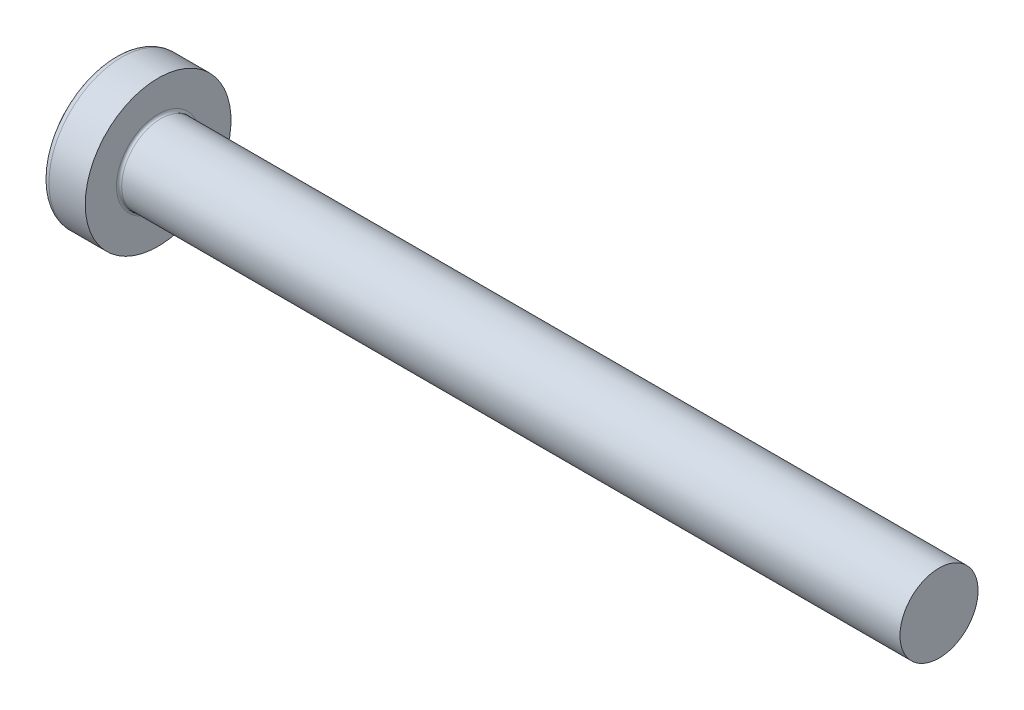
from build123d import *

# Parameters (mm, degrees)
FILLET1_R    = 0.1
SKETCH3_W    = 0.74
SKETCH3_H    = 2.8
SKETCH4_W    = 0.74
SKETCH4_H    = 1.054964432
RECPAT_COUNT = 2
RECPAT_ANGLE = 90


with BuildPart() as part:
    # BodySke → Base-Revolve (revolve)
    with BuildSketch(Plane.XY):
        with BuildLine():
            Line((2.4, 1.5), (2.4, 2.8))
            Line((2.4, 2.8), (1.003501533, 2.8))
            ThreePointArc((1.003501533, 2.8), (0.873295971, 2.76653015), (0.775371599, 2.674418605))
            ThreePointArc((0.775371599, 2.674418605), (0.197753546, 1.392274756), (0, 0))
            Line((0, 0), (32.4, 0))
            Line((32.4, 0), (32.4, 1.5))
            Line((32.4, 1.5), (2.4, 1.5))
        make_face()
    revolve(axis=Axis((-25.4, 0, 0), (1, 0, 0)))

    # Fillet1
    fillet1_edges = [part.edges().sort_by_distance(p)[0] for p in [
        (2.4, -1.5, 0),
    ]]
    fillet(fillet1_edges, radius=FILLET1_R)

    # Sketch3 → Recess section 0
    with BuildSketch(Plane(origin=(0, 0, 0), x_dir=(0, 0, -1), z_dir=(1, 0, 0))):
        Rectangle(SKETCH3_W, SKETCH3_H)
    # Sketch4 → Recess section 1
    with BuildSketch(Plane(origin=(1.75, 0, 0), x_dir=(0, 0, -1), z_dir=(1, 0, 0))):
        Rectangle(SKETCH4_W, SKETCH4_H)
    recess = loft(mode=Mode.SUBTRACT)

    # RecPat: Recess ×2 about axis
    recpat_axis = Axis((0, 0, 0), (1, 0, 0))
    for i in range(1, RECPAT_COUNT):
        add(recess.rotate(recpat_axis, i * RECPAT_ANGLE / (RECPAT_COUNT - 1)), mode=Mode.SUBTRACT)

    # RecCorSke → RecessCore (revolve, cut)
    with BuildSketch(Plane.XY):
        Polygon((0, 0), (0, 0.678371921), (1.75, 0.556), (1.930655351, 0), align=None)
    revolve(axis=Axis((-3.175, 0, 0), (1, 0, 0)), mode=Mode.SUBTRACT)


solid = part.part
